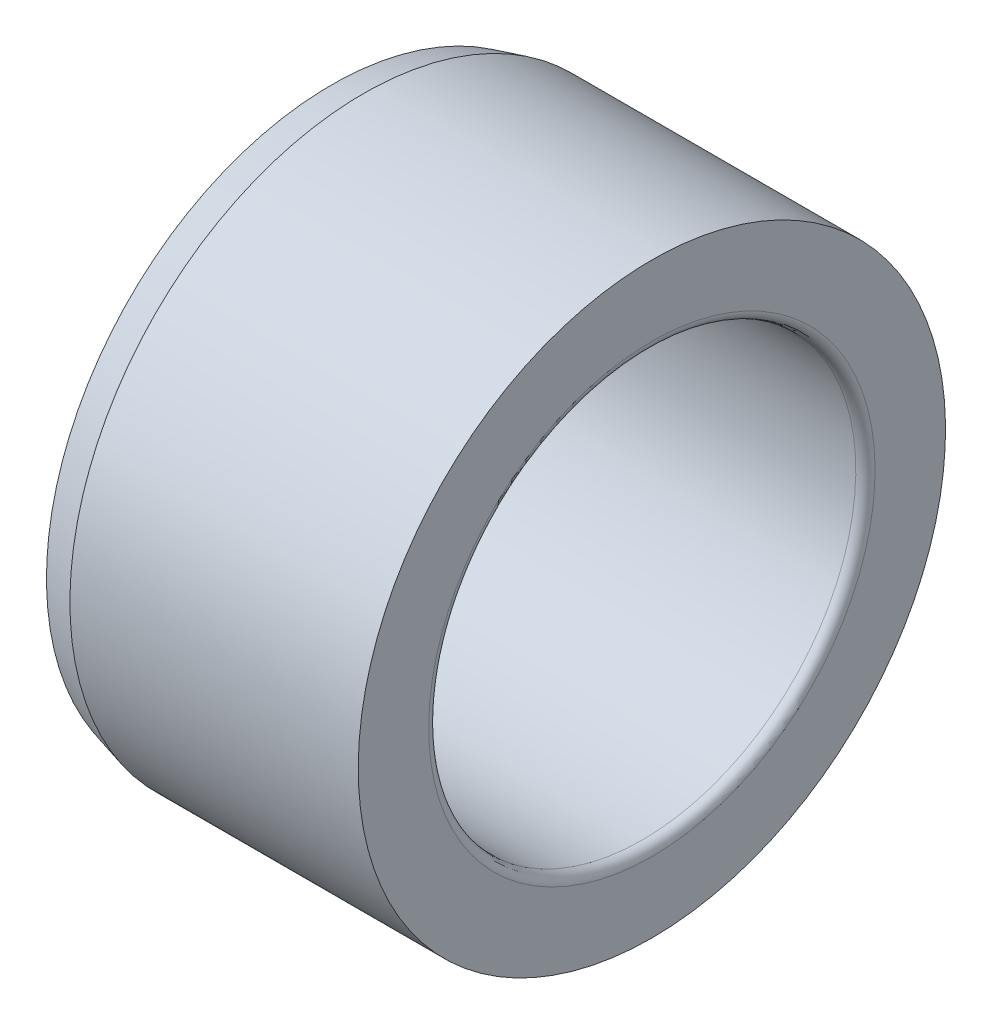
from build123d import *


with BuildPart() as part:
    # Sketch1 → Revolve1 (revolve)
    with BuildSketch(Plane.XY):
        with BuildLine():
            Line((-9.525, 16.952056788), (-7.62, 17.4625))
            Line((-7.62, 17.4625), (9.525, 17.4625))
            Line((9.525, 17.4625), (9.525, 13.2715))
            ThreePointArc((9.525, 13.2715), (9.357611525, 12.867388475), (8.9535, 12.7))
            Line((8.9535, 12.7), (-9.525, 12.7))
            Line((-9.525, 12.7), (-9.525, 16.952056788))
        make_face()
    revolve(axis=Axis((-9.525, 0, 0), (1, 0, 0)))


solid = part.part
